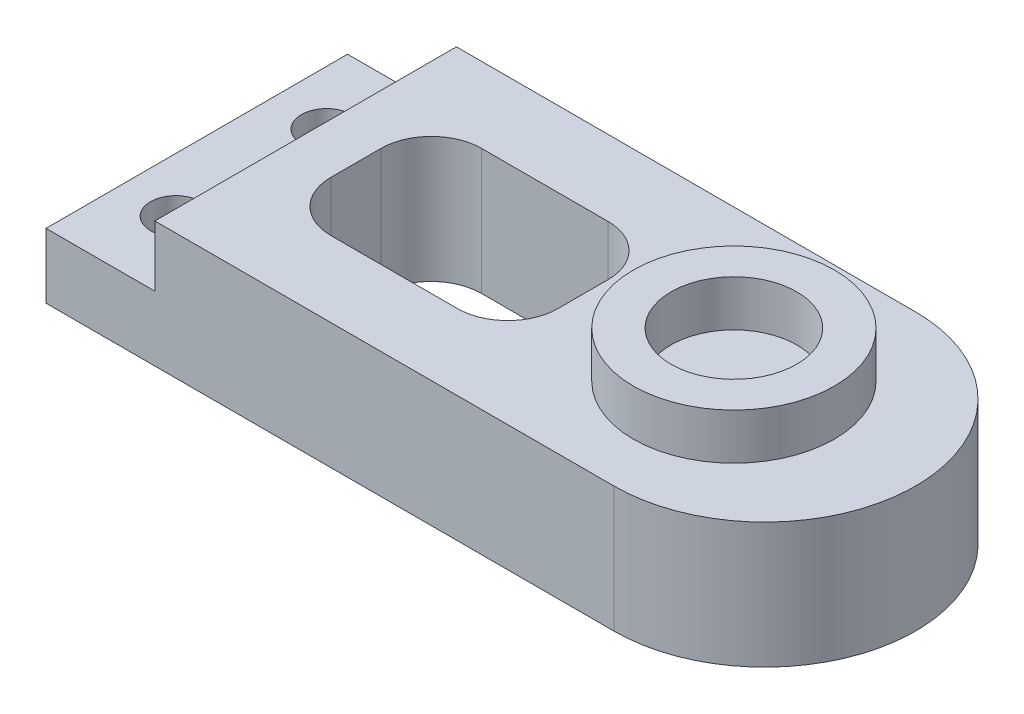
from build123d import *

# Parameters (mm, degrees)
BOSS_EXTRUDE1_DEPTH = 5
SKETCH2_W           = 4.33
SKETCH2_H           = 12
CUT_EXTRUDE1_DEPTH  = 2.42
SKETCH3_R           = 1
CUT_EXTRUDE2_DEPTH  = 3.58
SKETCH5_R           = 4
SKETCH5_R_2         = 2.5
BOSS_EXTRUDE2_DEPTH = 1.83
CUT_EXTRUDE3_DEPTH  = 6


with BuildPart() as part:
    # Sketch1 → Boss-Extrude1 (new body)
    with BuildSketch(Plane(origin=(0, 0, 0), x_dir=(1, 0, 0), z_dir=(0, 1, 0))):
        with BuildLine():
            Line((0, 0), (22.6, 0))
            ThreePointArc((22.6, 0), (28.6, 6), (22.6, 12))
            Line((22.6, 12), (0, 12))
            Line((0, 12), (0, 0))
        make_face()
    extrude(amount=BOSS_EXTRUDE1_DEPTH)

    # Sketch2 → Cut-Extrude1 (cut)
    with BuildSketch(Plane(origin=(0, 5, 0), x_dir=(1, 0, 0), z_dir=(0, 1, 0))):
        with Locations((2.165, 6)):
            Rectangle(SKETCH2_W, SKETCH2_H)
    extrude(amount=-CUT_EXTRUDE1_DEPTH, mode=Mode.SUBTRACT)

    # Sketch3 → Cut-Extrude2 (cut, through all)
    with BuildSketch(Plane(origin=(0, 2.58, 0), x_dir=(1, 0, 0), z_dir=(0, 1, 0))):
        with Locations((2.16, 9)):
            Circle(SKETCH3_R)
        with Locations((2.16, 3)):
            Circle(SKETCH3_R)
    extrude(amount=-CUT_EXTRUDE2_DEPTH, mode=Mode.SUBTRACT)

    # Sketch5 → Boss-Extrude2 (add)
    with BuildSketch(Plane(origin=(0, 5, 0), x_dir=(1, 0, 0), z_dir=(0, 1, 0))):
        with Locations((21.37, 6)):
            Circle(SKETCH5_R)
        with Locations((21.37, 6)):
            Circle(SKETCH5_R_2, mode=Mode.SUBTRACT)
    extrude(amount=BOSS_EXTRUDE2_DEPTH)

    # Sketch6 → Cut-Extrude3 (cut, through all)
    with BuildSketch(Plane(origin=(0, 5, 0), x_dir=(1, 0, 0), z_dir=(0, 1, 0))):
        with BuildLine():
            Line((8.33, 9), (13.37, 9))
            ThreePointArc((13.37, 9), (14.784213562, 8.414213562), (15.37, 7))
            Line((15.37, 7), (15.37, 5))
            ThreePointArc((15.37, 5), (14.784213562, 3.585786438), (13.37, 3))
            Line((13.37, 3), (8.33, 3))
            ThreePointArc((8.33, 3), (6.915786438, 3.585786438), (6.33, 5))
            Line((6.33, 5), (6.33, 7))
            ThreePointArc((6.33, 7), (6.915786438, 8.414213562), (8.33, 9))
        make_face()
    extrude(amount=-CUT_EXTRUDE3_DEPTH, mode=Mode.SUBTRACT)


solid = part.part
